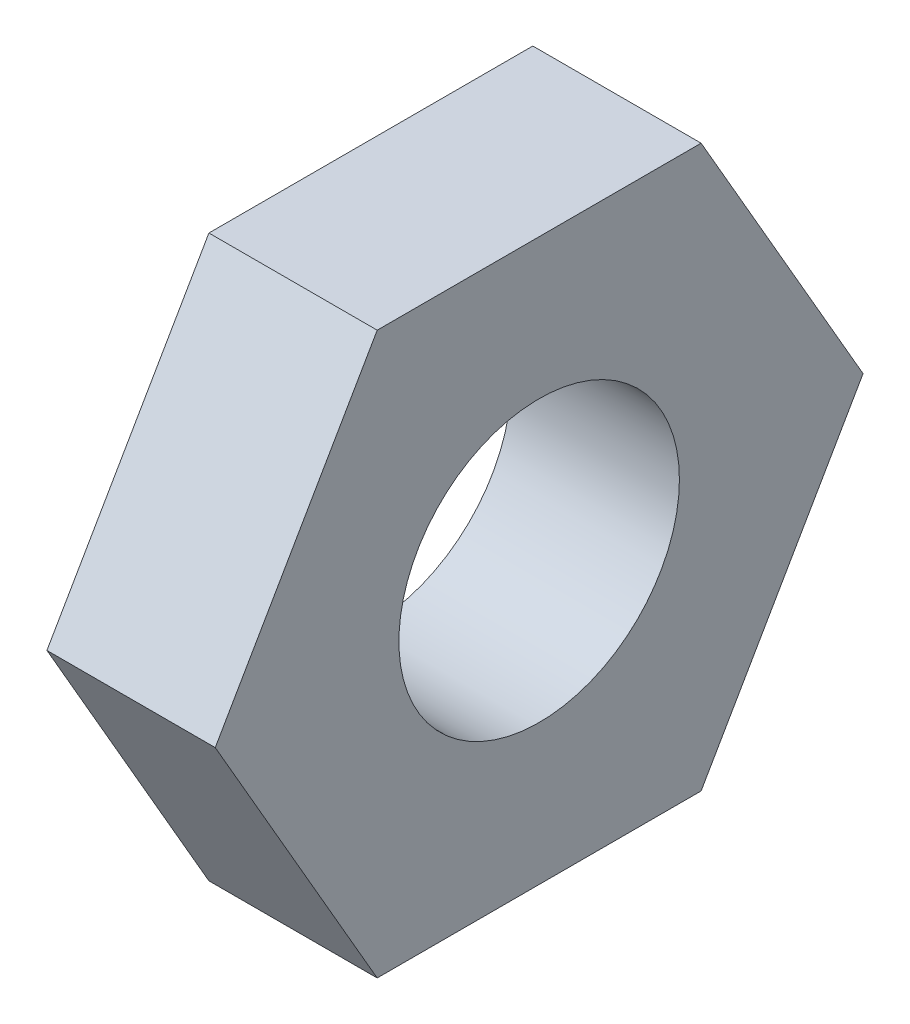
from build123d import *

# Parameters (mm, degrees)
SKETCH1_R           = 2.5
BOSS_EXTRUDE1_DEPTH = 3
SCALE1_SCALE        = 0.5


with BuildPart() as part:
    # Sketch1 → Boss-Extrude1 (new body)
    with BuildSketch(Plane(origin=(0, 0, 0), x_dir=(0, 0, -1), z_dir=(1, 0, 0))):
        Polygon((5.773502692, 0), (2.886751346, 5), (-2.886751346, 5), (-5.773502692, 0), (-2.886751346, -5), (2.886751346, -5), align=None)
        Circle(SKETCH1_R, mode=Mode.SUBTRACT)
    extrude(amount=BOSS_EXTRUDE1_DEPTH)


with BuildPart() as part_1:
    # Scale1: scaled about (0, 0, 0)
    add(part.part.scale(SCALE1_SCALE))


solid = part_1.part
